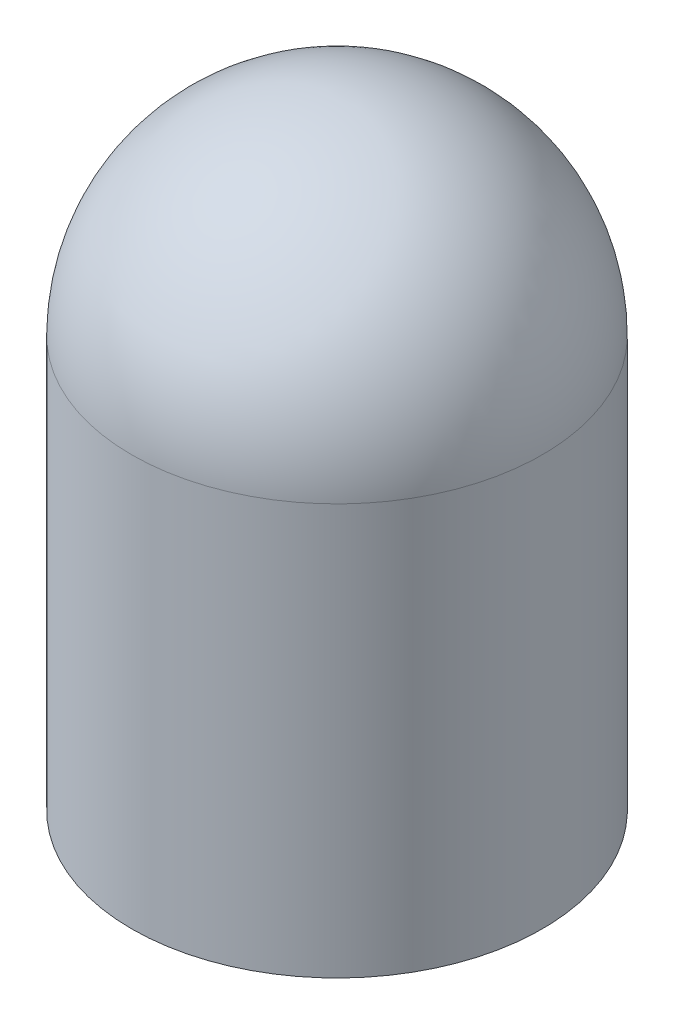
from build123d import *

# Parameters (mm, degrees)
SKETCH1_R      = 3.175
EXTRUDE1_DEPTH = 9.525
FILLET1_R      = 3.175


with BuildPart() as part:
    # Sketch1 → Extrude1 (new body)
    with BuildSketch(Plane(origin=(0, 0, 0), x_dir=(1, 0, 0), z_dir=(0, 1, 0))):
        with Locations(Location((0, 0, 0), (0, 0, 270))):  # turned: the seam where the file's is
            Circle(SKETCH1_R)
    extrude(amount=EXTRUDE1_DEPTH)

    # Fillet1
    fillet1_edges = [part.edges().sort_by_distance(p)[0] for p in [
        (0, 9.525, -3.175),
    ]]
    fillet(fillet1_edges, radius=FILLET1_R)


solid = part.part
